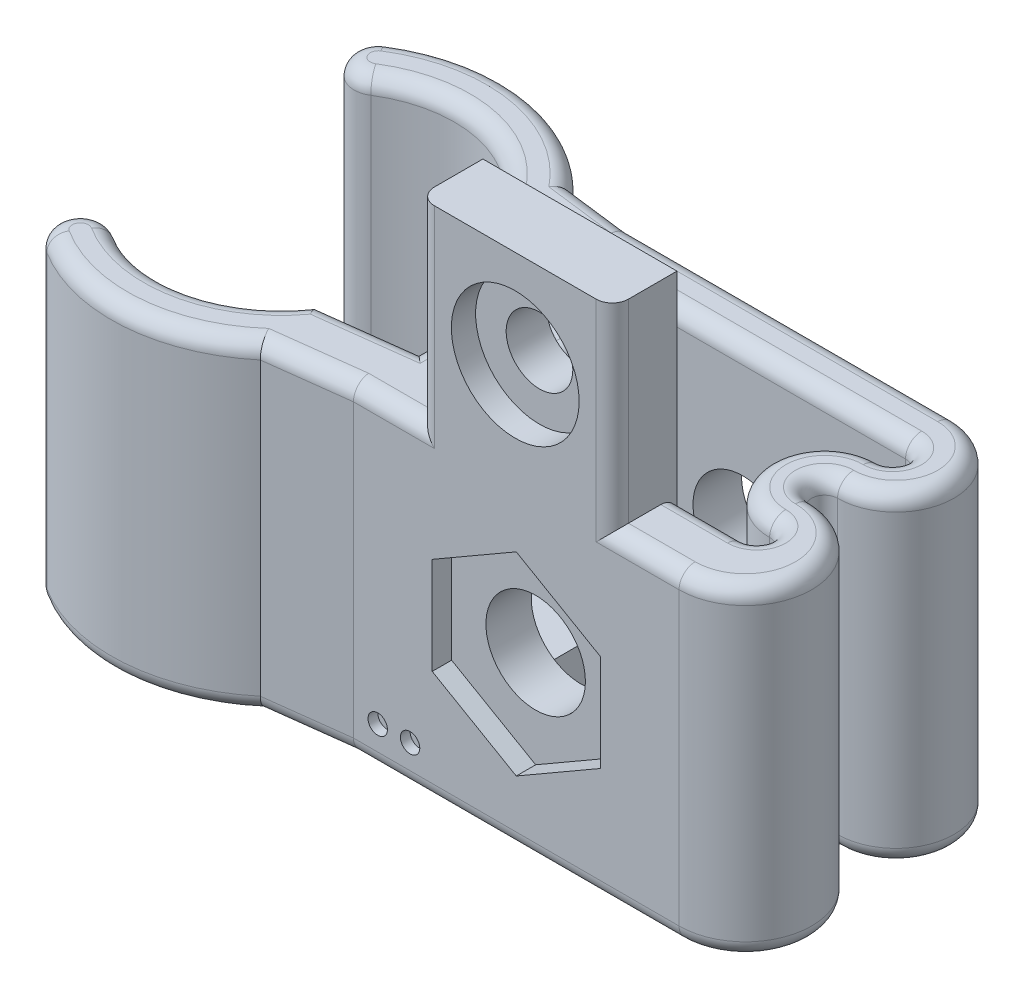
from build123d import *

# Parameters (mm, degrees)
BOSS_EXTRUDE1_DEPTH = 20
SKETCH3_R           = 3.075
CUT_EXTRUDE1_DEPTH  = 46.904466014
CUT_EXTRUDE2_DEPTH  = 1.2
SKETCH5_W           = 12
SKETCH5_H           = 4
BOSS_EXTRUDE2_DEPTH = 12
SKETCH6_R           = 2.06
CUT_EXTRUDE3_DEPTH  = 53.653774793
BOSS_EXTRUDE3_DEPTH = 4
BOSS_EXTRUDE4_START = -16
BOSS_EXTRUDE4_DEPTH = 4
SKETCH8_R           = 3.95
CUT_EXTRUDE4_DEPTH  = 1.5
FILLET1_R           = 1
FILLET7_R           = 1
FILLET10_R          = 1
FILLET11_R          = 1
SKETCH9_R           = 0.6
CUT_EXTRUDE5_DEPTH  = 0.6


with BuildPart() as part:
    # Sketch2 → Boss-Extrude1 (new body)
    with BuildSketch(Plane(origin=(0, 0, 0), x_dir=(1, 0, 0), z_dir=(0, 1, 0))):
        with BuildLine():
            Line((11.873863542, 5), (32, 5))
            ThreePointArc((32, 5), (32.8, 4.2), (32, 3.4))
            ThreePointArc((32, 3.4), (28.6, 0), (32, -3.4))
            ThreePointArc((32, -3.4), (32.8, -4.2), (32, -5))
            Line((32, -5), (11.873863542, -5))
            Line((11.873863542, -5), (6.280127387, -5.7))
            ThreePointArc((6.280127387, -5.7), (1.599672856, -8.927417468), (-4, -7.94428877))
            ThreePointArc((-4, -7.94428877), (-6.068857754, -8.413146524), (-5.6, -10.482004278))
            ThreePointArc((-5.6, -10.482004278), (0.713314262, -12.075742588), (6.752315105, -9.640910441))
            Line((6.752315105, -9.640910441), (11.873863542, -9))
            Line((11.873863542, -9), (32, -9))
            ThreePointArc((32, -9), (36.1, -4.9), (32, -0.8))
            ThreePointArc((32, -0.8), (31.2, 0), (32, 0.8))
            ThreePointArc((32, 0.8), (35.6, 4.4), (32, 8))
            Line((32, 8), (11.873863542, 8))
            Line((11.873863542, 8), (7.918974072, 8.494914768))
            ThreePointArc((7.918974072, 8.494914768), (1.52693856, 11.988380944), (-5.6, 10.482004278))
            ThreePointArc((-5.6, 10.482004278), (-6.068857754, 8.413146524), (-4, 7.94428877))
            ThreePointArc((-4, 7.94428877), (1.599672856, 8.927417468), (6.280127387, 5.7))
            Line((6.280127387, 5.7), (11.873863542, 5))
        make_face()
    extrude(amount=BOSS_EXTRUDE1_DEPTH)

    # Sketch3 → Cut-Extrude1 (cut, through all)
    with BuildSketch(Plane(origin=(0, 0, -8), x_dir=(-1, 0, 0), z_dir=(0, 0, -1))):
        with Locations((-21.936931771, 10)):
            Circle(SKETCH3_R)
    extrude(amount=-CUT_EXTRUDE1_DEPTH, mode=Mode.SUBTRACT)

    # Sketch4 → Cut-Extrude2 (cut)
    with BuildSketch(Plane.XY.offset(9)):
        Polygon((21.936931771, 4), (27.133084194, 7), (27.133084194, 13), (21.936931771, 16), (16.740779349, 13), (16.740779349, 7), align=None)
    extrude(amount=-CUT_EXTRUDE2_DEPTH, mode=Mode.SUBTRACT)

    # Sketch5 → Boss-Extrude2 (add)
    with BuildSketch(Plane(origin=(0, 20, 0), x_dir=(1, 0, 0), z_dir=(0, 1, 0))):
        with Locations((21.873863542, -7)):
            Rectangle(SKETCH5_W, SKETCH5_H)
    extrude(amount=BOSS_EXTRUDE2_DEPTH)

    # Sketch6 → Cut-Extrude3 (cut, through all)
    with BuildSketch(Plane.XY.offset(9)):
        with Locations((21.873863542, 26)):
            Circle(SKETCH6_R)
    extrude(amount=-CUT_EXTRUDE3_DEPTH, mode=Mode.SUBTRACT)

    # Sketch7 → Boss-Extrude3 (add)
    with BuildSketch(Plane.XZ):
        Polygon((11.873863542, 5), (11.873863542, -1.6), (16.873863542, -2.1), (16.873863542, 5), align=None)
    extrude(amount=-BOSS_EXTRUDE3_DEPTH)

    # Sketch7_2 → Boss-Extrude4 (add)
    with BuildSketch(Plane.XZ.offset(BOSS_EXTRUDE4_START)):
        Polygon((11.873863542, 5), (11.873863542, -1.6), (16.873863542, -2.1), (16.873863542, 5), align=None)
    extrude(amount=-BOSS_EXTRUDE4_DEPTH)

    # Sketch8 → Cut-Extrude4 (cut)
    with BuildSketch(Plane.XY.offset(9)):
        with Locations((21.873863542, 26)):
            Circle(SKETCH8_R)
    extrude(amount=-CUT_EXTRUDE4_DEPTH, mode=Mode.SUBTRACT)

    # Fillet1
    fillet1_edges = [part.edges().sort_by_distance(p)[0] for p in [
        (28.6, 0, 0),
        (32.8, 0, 4.2),
        (24.436931771, 0, 5),
        (16.873863542, 0, 1.45),
        (14.373863542, 0, -1.85),
        (11.873863542, 0, 1.7),
        (1.599672856, 0, 8.927417468),
        (-6.068857754, 0, 8.413146524),
        (0.713314262, 0, 12.075742588),
        (21.936931771, 0, 9),
        (36.1, 0, 4.9),
        (31.2, 0, 0),
        (35.6, 0, -4.4),
        (21.936931771, 0, -8),
        (1.52693856, 0, -11.988380944),
        (-6.068857754, 0, -8.413146524),
        (1.599672856, 0, -8.927417468),
        (21.936931771, 0, -5),
        (32.8, 0, -4.2),
        (9.896418807, 0, -8.247457384),
        (9.076995465, 0, -5.35),
        (9.076995465, 0, 5.35),
        (9.313089324, 0, 9.320455221),
    ]]
    fillet(fillet1_edges, radius=FILLET1_R)

    # Fillet7
    fillet7_edges = [part.edges().sort_by_distance(p)[0] for p in [
        (15.873863542, 26, 9),
        (27.873863542, 26, 9),
    ]]
    fillet(fillet7_edges, radius=FILLET7_R)

    # Fillet10
    fillet10_edges = [part.edges().sort_by_distance(p)[0] for p in [
        (21.936931771, 20, -8),
        (35.6, 20, -4.4),
        (31.2, 20, 0),
        (36.1, 20, 4.9),
        (29.436931771, 20, 9),
        (32.8, 20, 4.2),
        (28.6, 20, 0),
        (32.8, 20, -4.2),
        (21.936931771, 20, -5),
        (9.076995465, 20, -5.35),
        (1.599672856, 20, -8.927417468),
        (-6.068857754, 20, -8.413146524),
        (1.52693856, 20, -11.988380944),
        (9.896418807, 20, -8.247457384),
        (29.936931771, 20, 5),
    ]]
    fillet(fillet10_edges, radius=FILLET10_R)

    # Fillet11
    fillet11_edges = [part.edges().sort_by_distance(p)[0] for p in [
        (14.373863542, 20, 9),
        (9.313089324, 20, 9.320455221),
        (0.713314262, 20, 12.075742588),
        (-6.068857754, 20, 8.413146524),
        (1.599672856, 20, 8.927417468),
        (9.076995465, 20, 5.35),
        (16.873863542, 20, 1.45),
        (14.373863542, 20, -1.85),
        (11.873863542, 20, 1.7),
    ]]
    fillet(fillet11_edges, radius=FILLET11_R)

    # Sketch9 → Cut-Extrude5 (cut)
    with BuildSketch(Plane.XY.offset(9)):
        with Locations((13.373863542, 2.5)):
            Circle(SKETCH9_R)
        with Locations((15.373863542, 2.5)):
            Circle(SKETCH9_R)
    extrude(amount=-CUT_EXTRUDE5_DEPTH, mode=Mode.SUBTRACT)


solid = part.part
